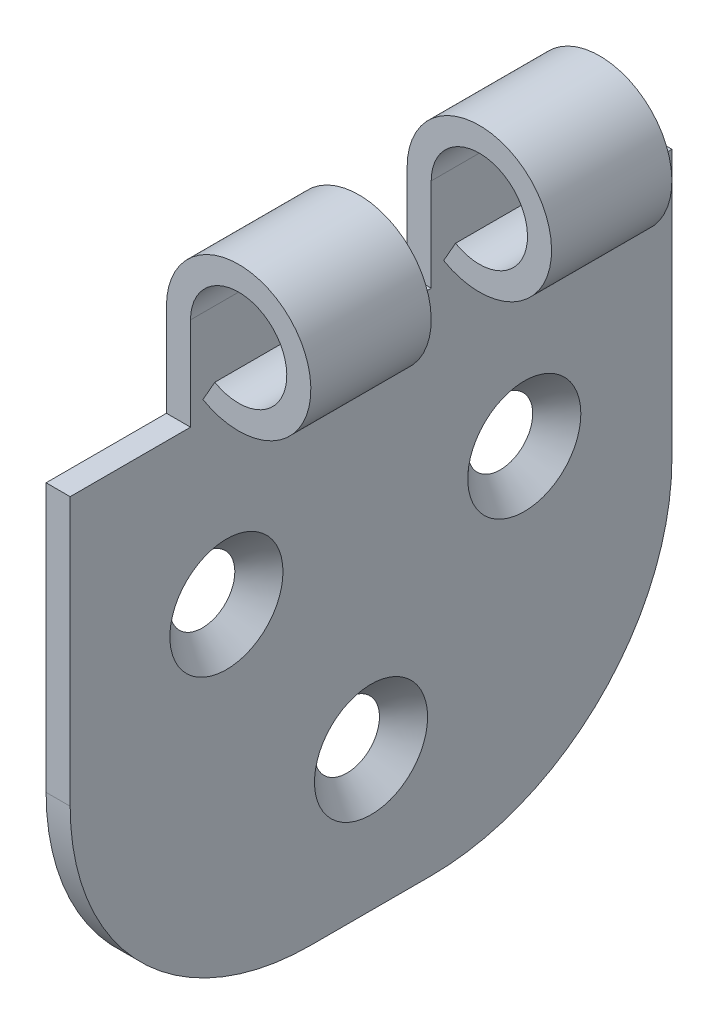
from build123d import *

# Parameters (mm, degrees)
BOSS_EXTRUDE1_DEPTH                          = 25
SKETCH2_W                                    = 13.175144841
SKETCH2_H                                    = 18.76358654
SKETCH2_W_2                                  = 10
SKETCH2_W_3                                  = 19.622994234
CUT_EXTRUDE1_DEPTH                           = 11
CUT_EXTRUDE1_DEPTH_BACK                      = 3
FILLET1_R                                    = 20
CSK_FOR_M4_COUNTERSUNK_FLAT_HEAD_SCR_2_COUNT = 2
CSK_FOR_M4_COUNTERSUNK_FLAT_HEAD_SCR_2_PITCH = 20.373860658
CSK_FOR_M4_COUNTERSUNK_FLAT_HEAD_SCR_3_COUNT = 2
CSK_FOR_M4_COUNTERSUNK_FLAT_HEAD_SCR_3_PITCH = 20.021215351


with BuildPart() as part:
    # Sketch1 → Boss-Extrude1 (new body, symmetric)
    with BuildSketch(Plane.XY):
        with BuildLine():
            Line((0, 0), (0, 50))
            ThreePointArc((0, 50), (11.186683916, 53.016340491), (3.032769985, 44.785065097))
            Line((3.032769985, 44.785065097), (4.021846657, 46.523376732))
            ThreePointArc((4.021846657, 46.523376732), (9.457789277, 52.01089366), (2, 50))
            Line((2, 50), (2, 0))
            Line((2, 0), (0, 0))
        make_face()
    extrude(amount=BOSS_EXTRUDE1_DEPTH, both=True)

    # Sketch2 → Cut-Extrude1 (cut, two sides)
    with BuildSketch(Plane(origin=(2, 0, 0), x_dir=(0, 0, -1), z_dir=(1, 0, 0))) as cut_extrude1_sk:
        with Locations((-21.587572421, 51.660780085)):
            Rectangle(SKETCH2_W, SKETCH2_H)
        with Locations((0, 51.660780085)):
            Rectangle(SKETCH2_W_2, SKETCH2_H)
        with Locations((24.811497117, 51.660780085)):
            Rectangle(SKETCH2_W_3, SKETCH2_H)
    extrude(amount=CUT_EXTRUDE1_DEPTH, mode=Mode.SUBTRACT)
    extrude(cut_extrude1_sk.sketch, amount=-CUT_EXTRUDE1_DEPTH_BACK, mode=Mode.SUBTRACT)

    # Fillet1
    fillet1_edges = [part.edges().sort_by_distance(p)[0] for p in [
        (1, 0, 25),
        (1, 0, -25),
    ]]
    fillet(fillet1_edges, radius=FILLET1_R)

    # Sketch4 → CSK for M4 Countersunk Flat Head Screw1 (revolve, cut)
    with BuildSketch(Plane(origin=(2, 11.587467643, 0), x_dir=(0, 0, -1), z_dir=(0, 1, 0))):
        Polygon((0, 0), (0, 2), (2.25, 2), (2.25, 2.45), (4.7, 0), align=None)
    csk_for_m4_countersunk_flat_head_screw1 = revolve(axis=Axis((8.35, 11.587467643, 0), (-1, 0, 0)), mode=Mode.SUBTRACT)

    # CSK for M4 Countersunk Flat Head Scr 2: CSK for M4 Countersunk Flat Head Screw1 ×2
    with Locations(*[Vector(0, 0.807519759, 0.58984052) * (i * CSK_FOR_M4_COUNTERSUNK_FLAT_HEAD_SCR_2_PITCH) for i in range(1, CSK_FOR_M4_COUNTERSUNK_FLAT_HEAD_SCR_2_COUNT)]):
        add(csk_for_m4_countersunk_flat_head_screw1, mode=Mode.SUBTRACT)

    # CSK for M4 Countersunk Flat Head Scr 3: CSK for M4 Countersunk Flat Head Screw1 ×2
    with Locations(*[Vector(0, 0.77172393, -0.635957683) * (i * CSK_FOR_M4_COUNTERSUNK_FLAT_HEAD_SCR_3_PITCH) for i in range(1, CSK_FOR_M4_COUNTERSUNK_FLAT_HEAD_SCR_3_COUNT)]):
        add(csk_for_m4_countersunk_flat_head_screw1, mode=Mode.SUBTRACT)


solid = part.part
